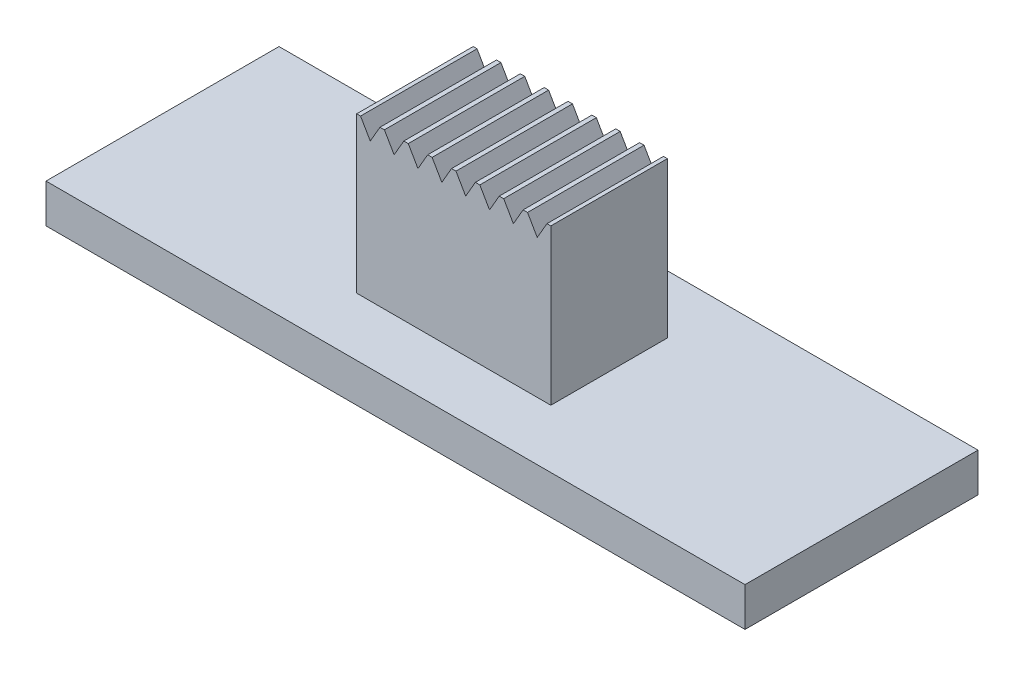
from build123d import *

# Parameters (mm, degrees)
SKETCH1_W           = 18
SKETCH1_H           = 6
BOSS_EXTRUDE1_DEPTH = 1
SKETCH2_W           = 5
SKETCH2_H           = 3
BOSS_EXTRUDE2_DEPTH = 4
CUT_EXTRUDE1_START  = -5.5
CUT_EXTRUDE1_DEPTH  = 8
LPATTERN1_COUNT     = 8
LPATTERN1_PITCH     = 0.614285714


with BuildPart() as part:
    # Sketch1 → Boss-Extrude1 (new body)
    with BuildSketch(Plane(origin=(0, 0, 0), x_dir=(1, 0, 0), z_dir=(0, 1, 0))):
        Rectangle(SKETCH1_W, SKETCH1_H)
    extrude(amount=BOSS_EXTRUDE1_DEPTH)

    # Sketch2 → Boss-Extrude2 (add)
    with BuildSketch(Plane(origin=(0, 1, 0), x_dir=(1, 0, 0), z_dir=(0, 1, 0))):
        Rectangle(SKETCH2_W, SKETCH2_H)
    extrude(amount=BOSS_EXTRUDE2_DEPTH)

    # Sketch3 → Cut-Extrude1 (cut)
    with BuildSketch(Plane.XY.offset(1.5).offset(CUT_EXTRUDE1_START)):
        Polygon((-2.15, 4.566987298), (-1.9, 5), (-2.4, 5), align=None)
    cut_extrude1 = extrude(amount=CUT_EXTRUDE1_DEPTH, mode=Mode.SUBTRACT)

    # LPattern1: Cut-Extrude1 ×8
    with Locations(*[(i * LPATTERN1_PITCH, 0, 0) for i in range(1, LPATTERN1_COUNT)]):
        add(cut_extrude1, mode=Mode.SUBTRACT)


solid = part.part
